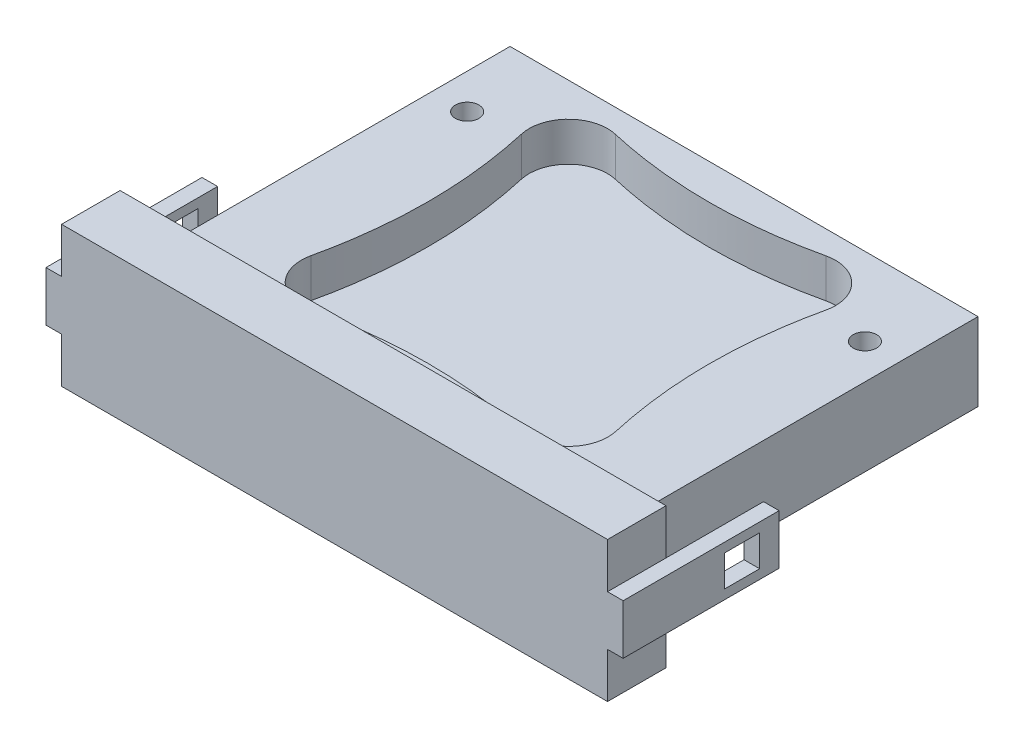
from build123d import *

# Parameters (mm, degrees)
SKETCH1_W           = 60
SKETCH1_H           = 45
BOSS_EXTRUDE1_DEPTH = 10
SKETCH2_W           = 70
SKETCH2_H           = 18
BOSS_EXTRUDE2_DEPTH = 7.5
CUT_EXTRUDE1_DEPTH  = 5
SKETCH4_W           = 4.5
SKETCH4_H           = 4
BOSS_EXTRUDE3_DEPTH = 2
SKETCH5_R           = 1.5
CUT_EXTRUDE2_DEPTH  = 15


with BuildPart() as part:
    # Sketch1 → Boss-Extrude1 (new body)
    with BuildSketch(Plane(origin=(0, 0, 0), x_dir=(1, 0, 0), z_dir=(0, 1, 0))):
        Rectangle(SKETCH1_W, SKETCH1_H)
    extrude(amount=BOSS_EXTRUDE1_DEPTH)

    # Sketch2 → Boss-Extrude2 (add)
    with BuildSketch(Plane.XY.offset(22.5)):
        with Locations((0, 5)):
            Rectangle(SKETCH2_W, SKETCH2_H)
    extrude(amount=BOSS_EXTRUDE2_DEPTH)

    # Sketch3 → Cut-Extrude1 (cut)
    with BuildSketch(Plane(origin=(0, 10, 0), x_dir=(1, 0, 0), z_dir=(0, 1, 0))):
        with BuildLine():
            ThreePointArc((-19.5325, -13.495), (-18.170661955, -18.166166123), (-13.49, -19.495))
            add(Edge.make_bspline(
                [(-13.49, -19.495), (-4.496666667, -17.441666667), (4.496666667, -17.441666667), (13.49, -19.495)],
                knots=[0, 0, 0, 0, 1, 1, 1, 1], degree=3))
            ThreePointArc((13.49, -19.495), (18.162524477, -18.157971004), (19.5325, -13.495))
            add(Edge.make_bspline(
                [(19.5325, 13.495), (16.4925, 0), (19.5325, -13.495)],
                knots=[0, 0, 0, 1, 1, 1], degree=2))
            ThreePointArc((19.5325, 13.495), (18.162524477, 18.157971004), (13.49, 19.495))
            add(Edge.make_bspline(
                [(-13.49, 19.495), (-4.496666667, 17.441666667), (4.496666667, 17.441666667), (13.49, 19.495)],
                knots=[0, 0, 0, 0, 1, 1, 1, 1], degree=3))
            ThreePointArc((-13.49, 19.495), (-18.170661955, 18.166166123), (-19.5325, 13.495))
            add(Edge.make_bspline(
                [(-19.5325, 13.495), (-18.519166667, 8.996666667), (-17.505833333, 0), (-18.519166667, -8.996666667), (-19.5325, -13.495)],
                knots=[0, 0, 0, 0, 0.5, 1, 1, 1, 1], degree=3))
        make_face()
    extrude(amount=-CUT_EXTRUDE1_DEPTH, mode=Mode.SUBTRACT)

    # Sketch4 → Boss-Extrude3 (add)
    with BuildSketch(Plane(origin=(35, 0, 0), x_dir=(0, 0, -1), z_dir=(1, 0, 0))):
        Polygon((-30, 5), (-30, 8.2), (-10, 8.2), (-10, 1.8), (-30, 1.8), align=None)
        with Locations((-14.75, 5)):
            Rectangle(SKETCH4_W, SKETCH4_H, mode=Mode.SUBTRACT)
    boss_extrude3 = extrude(amount=BOSS_EXTRUDE3_DEPTH)

    # Mirror1: Boss-Extrude3 across plane
    add(boss_extrude3.mirror(Plane(origin=(0, 0, 0), x_dir=(0, 0, 1), z_dir=(1, 0, 0))))

    # Sketch5 → Cut-Extrude2 (cut, through all)
    with BuildSketch(Plane(origin=(0, 10, 0), x_dir=(1, 0, 0), z_dir=(0, 1, 0))):
        with Locations((25.5, 12.5)):
            Circle(SKETCH5_R)
    cut_extrude2 = extrude(amount=-CUT_EXTRUDE2_DEPTH, mode=Mode.SUBTRACT)

    # Mirror2: Cut-Extrude2 across plane
    add(cut_extrude2.mirror(Plane(origin=(0, 0, 0), x_dir=(0, 0, 1), z_dir=(1, 0, 0))), mode=Mode.SUBTRACT)


solid = part.part
